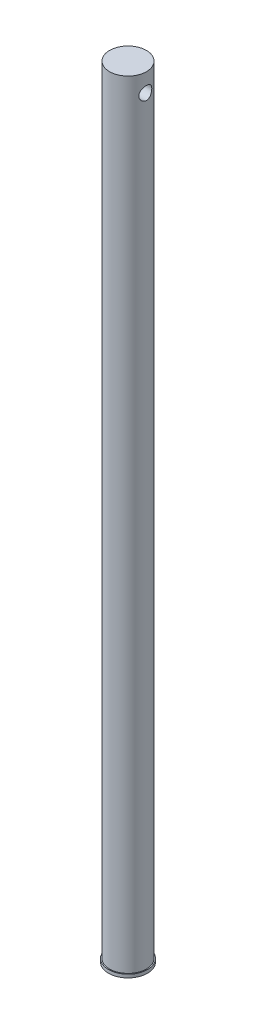
from build123d import *

# Parameters (mm, degrees)
SKETCH2_R               = 9
BOSS_EXTRUDE1_DEPTH     = 381
SKETCH3_R               = 9.5
BOSS_EXTRUDE2_DEPTH     = 1.5875
SKETCH4_R               = 3.175
CUT_EXTRUDE1_DEPTH      = 10.5
CUT_EXTRUDE1_DEPTH_BACK = 10.5


with BuildPart() as part:
    # Sketch2 → Boss-Extrude1 (new body)
    with BuildSketch(Plane(origin=(0, 0, 0), x_dir=(1, 0, 0), z_dir=(0, 1, 0))):
        Circle(SKETCH2_R)
    extrude(amount=BOSS_EXTRUDE1_DEPTH)

    # Sketch3 → Boss-Extrude2 (add)
    with BuildSketch(Plane.XZ):
        Circle(SKETCH3_R)
    extrude(amount=-BOSS_EXTRUDE2_DEPTH)

    # Sketch4 → Cut-Extrude1 (cut, two sides)
    with BuildSketch(Plane(origin=(0, 0, 0), x_dir=(0, 0, -1), z_dir=(1, 0, 0))) as cut_extrude1_sk:
        with Locations((0, 372)):
            Circle(SKETCH4_R)
    extrude(amount=CUT_EXTRUDE1_DEPTH, mode=Mode.SUBTRACT)
    extrude(cut_extrude1_sk.sketch, amount=-CUT_EXTRUDE1_DEPTH_BACK, mode=Mode.SUBTRACT)


solid = part.part
